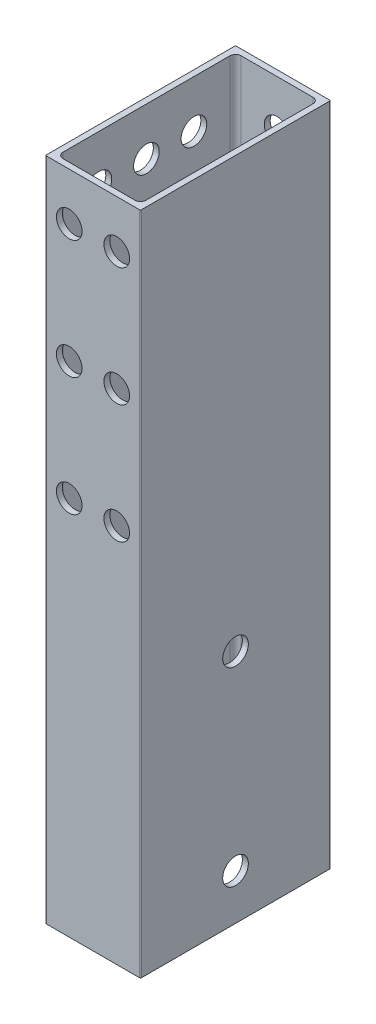
from build123d import *

# Parameters (mm, degrees)
BOSS_EXTRUDE1_DEPTH = 177.8
SKETCH2_R           = 10.16
SKETCH2_R_2         = 3.429
CUT_EXTRUDE1_DEPTH  = 12.7
SKETCH2_3_R         = 3.429
CUT_EXTRUDE2_DEPTH  = 187.6511184
SKETCH3_R           = 3.429
CUT_EXTRUDE3_DEPTH  = 2.54
SKETCH4_R           = 3.429
CUT_EXTRUDE4_DEPTH  = 2.54


with BuildPart() as part:
    # Sketch1 → Boss-Extrude1 (new body)
    with BuildSketch(Plane(origin=(0, 0, 0), x_dir=(1, 0, 0), z_dir=(0, 1, 0))):
        with BuildLine():
            Line((0.254, 50.8), (25.146, 50.8))
            ThreePointArc((25.146, 50.8), (25.325605122, 50.725605122), (25.4, 50.546))
            Line((25.4, 50.546), (25.4, 0.254))
            ThreePointArc((25.4, 0.254), (25.325605122, 0.074394878), (25.146, 0))
            Line((25.146, 0), (0.254, 0))
            ThreePointArc((0.254, 0), (0.074394878, 0.074394878), (0, 0.254))
            Line((0, 0.254), (0, 50.546))
            ThreePointArc((0, 50.546), (0.074394878, 50.725605122), (0.254, 50.8))
        make_face()
        with BuildLine():
            Line((1.5875, 3.1115), (1.5875, 47.6885))
            ThreePointArc((1.5875, 47.6885), (2.033869265, 48.766130735), (3.1115, 49.2125))
            Line((3.1115, 49.2125), (22.2885, 49.2125))
            ThreePointArc((22.2885, 49.2125), (23.366130735, 48.766130735), (23.8125, 47.6885))
            Line((23.8125, 47.6885), (23.8125, 3.1115))
            ThreePointArc((23.8125, 3.1115), (23.366130735, 2.033869265), (22.2885, 1.5875))
            Line((22.2885, 1.5875), (3.1115, 1.5875))
            ThreePointArc((3.1115, 1.5875), (2.033869265, 2.033869265), (1.5875, 3.1115))
        make_face(mode=Mode.SUBTRACT)
    extrude(amount=BOSS_EXTRUDE1_DEPTH)

    # Sketch2 → Cut-Extrude1 (cut)
    # profile 1 of 11: a face of its own
    with BuildSketch(Plane.ZY):
        with Locations((-25.4, 12.192)):
            Circle(SKETCH2_R)
        with Locations((-25.4, 12.192)):
            Circle(SKETCH2_R_2, mode=Mode.SUBTRACT)
    # profile 2 of 11: a face of its own
    with BuildSketch(Plane.ZY):
        with Locations((-25.4, 62.992)):
            Circle(SKETCH2_R)
        with Locations((-25.4, 62.992)):
            Circle(SKETCH2_R_2, mode=Mode.SUBTRACT)
    # profile 3 of 11: a face of its own
    with BuildSketch(Plane.ZY):
        with Locations((-38.1, 165.1)):
            Circle(SKETCH2_R_2)
    # profile 4 of 11: a face of its own
    with BuildSketch(Plane.ZY):
        with Locations((-25.4, 165.1)):
            Circle(SKETCH2_R_2)
    # profile 5 of 11: a face of its own
    with BuildSketch(Plane.ZY):
        with Locations((-12.7, 165.1)):
            Circle(SKETCH2_R_2)
    # profile 6 of 11: a face of its own
    with BuildSketch(Plane.ZY):
        with Locations((-25.4, 133.35)):
            Circle(SKETCH2_R_2)
    # profile 7 of 11: a face of its own
    with BuildSketch(Plane.ZY):
        with Locations((-12.7, 133.35)):
            Circle(SKETCH2_R_2)
    # profile 8 of 11: a face of its own
    with BuildSketch(Plane.ZY):
        with Locations((-25.4, 101.6)):
            Circle(SKETCH2_R_2)
    # profile 9 of 11: a face of its own
    with BuildSketch(Plane.ZY):
        with Locations((-12.7, 101.6)):
            Circle(SKETCH2_R_2)
    # profile 10 of 11: a face of its own
    with BuildSketch(Plane.ZY):
        with Locations((-38.1, 133.35)):
            Circle(SKETCH2_R_2)
    # profile 11 of 11: a face of its own
    with BuildSketch(Plane.ZY):
        with Locations((-38.1, 101.6)):
            Circle(SKETCH2_R_2)
    extrude(amount=-CUT_EXTRUDE1_DEPTH, mode=Mode.SUBTRACT)


with BuildPart() as cut_extrude1_piece_1:
    # of the separate pieces the step leaves, piece 1, a body of its own (cut_extrude1_pieces)
    add(part.part.solids().sort_by_distance((0, 0, -50.546))[0])


with BuildPart() as cut_extrude1_piece_2:
    # of the separate pieces the step leaves, piece 2, a body of its own (cut_extrude1_pieces)
    add(part.part.solids().sort_by_distance((0, 62.992, -21.971))[0])


with BuildPart() as cut_extrude1_piece_3:
    # of the separate pieces the step leaves, piece 3, a body of its own (cut_extrude1_pieces)
    add(part.part.solids().sort_by_distance((0, 12.192, -21.971))[0])


with BuildPart() as cut_extrude2_tool:
    # Sketch2_3 → Cut-Extrude2 (new, through all)
    with BuildSketch(Plane.ZY):
        with Locations((-25.4, 12.192)):
            Circle(SKETCH2_3_R)
        with Locations((-25.4, 62.992)):
            Circle(SKETCH2_3_R)
    extrude(amount=-CUT_EXTRUDE2_DEPTH)


with BuildPart() as cut_extrude1_piece_1_1:
    add(cut_extrude1_piece_1.part)

    # Cut-Extrude2: cut by cut_extrude2_tool
    add(cut_extrude2_tool.part, mode=Mode.SUBTRACT)

    # Sketch3 → Cut-Extrude3 (cut)
    with BuildSketch(Plane.XY):
        with Locations((19.05, 165.1)):
            Circle(SKETCH3_R)
        with Locations((6.35, 165.1)):
            Circle(SKETCH3_R)
        with Locations((6.35, 133.35)):
            Circle(SKETCH3_R)
        with Locations((6.35, 101.6)):
            Circle(SKETCH3_R)
        with Locations((19.05, 133.35)):
            Circle(SKETCH3_R)
        with Locations((19.05, 101.6)):
            Circle(SKETCH3_R)
    extrude(amount=-CUT_EXTRUDE3_DEPTH, mode=Mode.SUBTRACT)

    # Sketch4 → Cut-Extrude4 (cut)
    with BuildSketch(Plane(origin=(0, 0, -50.8), x_dir=(-1, 0, 0), z_dir=(0, 0, -1))):
        with Locations((-12.7, 165.1)):
            Circle(SKETCH4_R)
        with Locations((-12.7, 139.7)):
            Circle(SKETCH4_R)
        with Locations((-12.7, 127)):
            Circle(SKETCH4_R)
        with Locations((-12.7, 101.6)):
            Circle(SKETCH4_R)
    extrude(amount=-CUT_EXTRUDE4_DEPTH, mode=Mode.SUBTRACT)


with BuildPart() as cut_extrude1_piece_2_1:
    add(cut_extrude1_piece_2.part)

    # Cut-Extrude2: cut by cut_extrude2_tool
    add(cut_extrude2_tool.part, mode=Mode.SUBTRACT)


with BuildPart() as cut_extrude1_piece_3_1:
    add(cut_extrude1_piece_3.part)

    # Cut-Extrude2: cut by cut_extrude2_tool
    add(cut_extrude2_tool.part, mode=Mode.SUBTRACT)


solid = cut_extrude1_piece_1_1.part
